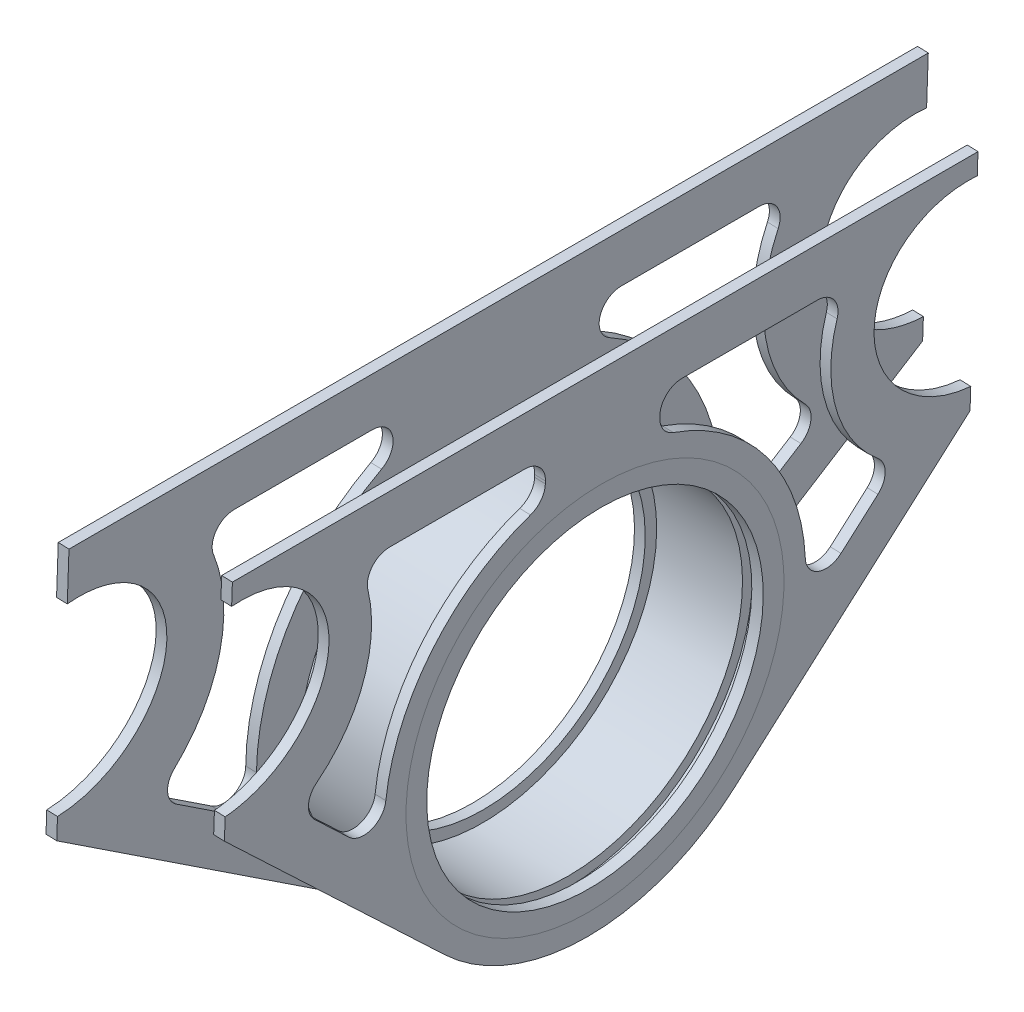
from build123d import *

# Parameters (mm, degrees)
SKETCH1_R                           = 12.7
SKETCH1_R_2                         = 10.668
STRUCTURAL_MEMBERLEFTDIAGTUBE_DEPTH = 435.613716129
EXTRUDEBEARINGCUP_START             = -8.2
SKETCH12_R                          = 26.4
SKETCH12_R_2                        = 23.5
EXTRUDEBEARINGCUP_DEPTH             = 16.4
SKETCH15_R                          = 23.5
SKETCH15_R_2                        = 21.9
BEARING_BACKSTOP_DEPTH              = 1.5
SKETCH24_R                          = 26.4
BOSS_EXTRUDEREARFLANGE_DEPTH        = 1.5
SKETCH16_R                          = 26.4
BOSS_EXTRUDEFRONTFLANGE_DEPTH       = 1.5
SKETCH20_R                          = 12.7
CUT_EXTRUDE1_DEPTH                  = 834.807291922
SKETCH26_R                          = 12.7
CUT_EXTRUDE2_DEPTH                  = 706.049293577


with BuildPart() as part:
    # Sketch1 → Structural MemberLeftDiagTube (new body)
    with BuildSketch(Plane(origin=(-742.278957466, 285.318954728, -26.691255907), x_dir=(0.4337677346733861, -0.1083105522192937, 0.894491127197062), z_dir=(-0.8944911271970621, -0.17110086067965116, 0.41304977767868617))):
        Circle(SKETCH1_R)
        Circle(SKETCH1_R_2, mode=Mode.SUBTRACT)
    extrude(amount=STRUCTURAL_MEMBERLEFTDIAGTUBE_DEPTH)


with BuildPart() as body_2:
    # MirrorRightDiagTube: mirrored copy
    add(part.part.mirror(Plane.XY.offset(-26.708200568)))


with BuildPart() as body_3:
    # Sketch12 → ExtrudeBearingCup (new body)
    with BuildSketch(Plane(origin=(-871.417099955, 30.430555679, 0), x_dir=(0, 0, -1), z_dir=(0.9993908270190963, -0.03489949670248751, 0)).offset(EXTRUDEBEARINGCUP_START)):
        with Locations(Location((26.708200568, 208.880792495, 0), (0, 0, 90))):
            Circle(SKETCH12_R)
        with Locations(Location((26.708200568, 208.880792495, 0), (0, 0, 90))):
            Circle(SKETCH12_R_2, mode=Mode.SUBTRACT)
    extrude(amount=EXTRUDEBEARINGCUP_DEPTH)

    # Sketch15 → Bearing Backstop (add)
    with BuildSketch(Plane(origin=(-879.612104737, 30.716731552, 0), x_dir=(0, 0, -1), z_dir=(0.9993908270190963, -0.034899496702487515, 0))):
        with Locations(Location((26.708200568, 208.880792495, 0), (0, 0, 90))):
            Circle(SKETCH15_R)
        with Locations(Location((26.708200568, 208.880792495, 0), (0, 0, 90))):
            Circle(SKETCH15_R_2, mode=Mode.SUBTRACT)
    extrude(amount=BEARING_BACKSTOP_DEPTH)

    # Sketch23 → Cut-RevolveSnapRingGroove (revolve, cut)
    with BuildSketch(Plane.XY.offset(-26.708200568), mode=Mode.PRIVATE) as cut_revolvesnapringgroove_sk:
        Polygon((-857.531285968, 238.953766961), (-858.400283436, 214.068935368), (-859.699491511, 214.114304714), (-858.830494043, 238.999136306), align=None)
    revolve(cut_revolvesnapringgroove_sk.sketch.rotate(Axis((-880.000118881, 239.738395896, -26.708200568), (0.9993908270190962, -0.03489949670248762, 0)), 180), axis=Axis((-880.000118881, 239.738395896, -26.708200568), (0.9993908270190962, -0.03489949670248762, 0)), mode=Mode.SUBTRACT)


with BuildPart() as body_4:
    # Sketch24 → Boss-ExtrudeRearFlange (new body)
    with BuildSketch(Plane(origin=(-863.222095173, 30.144379806, 0), x_dir=(0, 0, -1), z_dir=(0.9993908270190963, -0.034899496702487515, 0))):
        with BuildLine():
            Line((78.806239974, 246.71090197), (78.806239974, 249.71090197))
            Line((78.806239974, 249.71090197), (-25.389838838, 249.71090197))
            Line((-25.389838838, 249.71090197), (-25.389838838, 246.71090197))
            add(Edge.make_bspline(
                [(-25.389838838, 220.775104066), (-11.383096571, 221.994886497), (-11.383096571, 234.962785449), (-11.383096571, 247.930684401), (-25.389838838, 246.71090197)],
                knots=[1.160721876, 1.160721876, 1.160721876, 2.731518203, 2.731518203, 4.302314529, 4.302314529, 4.302314529], degree=2, weights=[1, 0.707106781, 1, 0.707106781, 1]))
            Line((-25.389838838, 220.775104066), (-25.389838838, 217.775104066))
            Line((-25.389838838, 217.775104066), (6.475538565, 187.550077826))
            ThreePointArc((6.475538565, 187.550077826), (26.708200568, 179.480792495), (46.94086257, 187.550077826))
            Line((46.94086257, 187.550077826), (78.806239974, 217.775104066))
            Line((78.806239974, 217.775104066), (78.806239974, 220.775104066))
            add(Edge.make_bspline(
                [(78.806239974, 246.71090197), (64.799497707, 247.930684401), (64.799497707, 234.962785449), (64.799497707, 221.994886497), (78.806239974, 220.775104066)],
                knots=[5.122463431, 5.122463431, 5.122463431, 6.693259758, 6.693259758, 8.264056085, 8.264056085, 8.264056085], degree=2, weights=[1, 0.707106781, 1, 0.707106781, 1]))
        make_face()
        with Locations(Location((26.708200568, 208.880792495, 0), (0, 0, 90))):
            Circle(SKETCH24_R, mode=Mode.SUBTRACT)
        with BuildLine():
            Line((-12.651994558, 213.962737757), (-7.658075134, 209.225893008))
            ThreePointArc((-7.658075134, 209.225893008), (-4.517205064, 208.602219609), (-2.602617939, 211.16900543))
            ThreePointArc((-2.602617939, 211.16900543), (3.323935367, 226.700336289), (16.726719086, 236.534544997))
            ThreePointArc((16.726719086, 236.534544997), (18.163353878, 237.632343071), (18.708200568, 239.356356477))
            Line((18.708200568, 239.356356477), (18.708200568, 239.71090197))
            ThreePointArc((18.708200568, 239.71090197), (17.829520911, 241.832222313), (15.708200568, 242.71090197))
            Line((15.708200568, 242.71090197), (-3.177585866, 242.71090197))
            ThreePointArc((-3.177585866, 242.71090197), (-5.558264845, 241.536379331), (-6.074836253, 238.932480367))
            ThreePointArc((-6.074836253, 238.932480367), (-6.310345755, 227.745258132), (-12.518185249, 218.435471084))
            ThreePointArc((-12.518185249, 218.435471084), (-13.5860956, 216.229051182), (-12.651994558, 213.962737757))
        make_face(mode=Mode.SUBTRACT)
        with BuildLine():
            Line((66.068395694, 213.962737757), (61.07447627, 209.225893008))
            ThreePointArc((61.07447627, 209.225893008), (57.9336062, 208.602219609), (56.019019075, 211.16900543))
            ThreePointArc((56.019019075, 211.16900543), (50.092465769, 226.700336289), (36.689682049, 236.534544997))
            ThreePointArc((36.689682049, 236.534544997), (35.253047257, 237.632343071), (34.708200568, 239.356356477))
            Line((34.708200568, 239.356356477), (34.708200568, 239.71090197))
            ThreePointArc((34.708200568, 239.71090197), (35.586880224, 241.832222313), (37.708200568, 242.71090197))
            Line((37.708200568, 242.71090197), (56.593987002, 242.71090197))
            ThreePointArc((56.593987002, 242.71090197), (58.974665981, 241.536379331), (59.491237389, 238.932480367))
            ThreePointArc((59.491237389, 238.932480367), (59.726746891, 227.745258132), (65.934586385, 218.435471084))
            ThreePointArc((65.934586385, 218.435471084), (67.002496736, 216.229051182), (66.068395694, 213.962737757))
        make_face(mode=Mode.SUBTRACT)
    extrude(amount=-BOSS_EXTRUDEREARFLANGE_DEPTH)


with BuildPart() as body_5:
    # Sketch16 → Boss-ExtrudeFrontFlange (new body)
    with BuildSketch(Plane(origin=(-879.612104737, 30.716731552, 0), x_dir=(0, 0, 1), z_dir=(-0.9993908270190963, 0.034899496702487515, 0))):
        with BuildLine():
            Line((33.333947306, 249.71090197), (-86.750348442, 249.71090197))
            Line((-86.750348442, 249.71090197), (-86.750348442, 242.945449778))
            add(Edge.make_bspline(
                [(-87.206665991, 216.992905829), (-72.667344737, 217.516199157), (-72.429971378, 231.01654018), (-72.192598019, 244.516881203), (-86.750348442, 242.945449778)],
                knots=[4.247183605, 4.247183605, 4.247183605, 5.856808636, 5.856808636, 7.466433668, 7.466433668, 7.466433668], degree=2, weights=[1, 0.693246367, 1, 0.693246367, 1]))
            Line((-87.206665991, 216.992905829), (-87.206665991, 213.992905829))
            Line((-87.206665991, 213.992905829), (-43.060097657, 184.4477112))
            ThreePointArc((-43.060097657, 184.4477112), (-26.709608396, 179.480792529), (-10.358643524, 184.446145281))
            Line((-10.358643524, 184.446145281), (33.798949952, 213.992595743))
            Line((33.798949952, 213.992595743), (33.798949952, 216.992595743))
            add(Edge.make_bspline(
                [(33.333947306, 242.945449778), (18.771672419, 244.517369595), (19.013641816, 231.012507832), (19.255611213, 217.50764607), (33.798949952, 216.992595743)],
                knots=[5.099936946, 5.099936946, 5.099936946, 6.709872488, 6.709872488, 8.319808029, 8.319808029, 8.319808029], degree=2, weights=[1, 0.693134466, 1, 0.693134466, 1]))
            Line((33.333947306, 242.945449778), (33.333947306, 249.71090197))
        make_face()
        with Locations(Location((-26.708200568, 208.880792495, 0), (0, 0, 270))):
            Circle(SKETCH16_R, mode=Mode.SUBTRACT)
        with BuildLine():
            Line((-70.339444305, 209.924197834), (-63.766251621, 205.52507318))
            ThreePointArc((-63.766251621, 205.52507318), (-60.652345168, 205.389371158), (-59.098581361, 208.091342008))
            ThreePointArc((-59.098581361, 208.091342008), (-54.884301087, 224.876646944), (-42.631108459, 237.098180828))
            ThreePointArc((-42.631108459, 237.098180828), (-41.203886392, 240.473081927), (-44.105451782, 242.71090197))
            Line((-44.105451782, 242.71090197), (-63.394456936, 242.71090197))
            ThreePointArc((-63.394456936, 242.71090197), (-65.89374993, 241.370279722), (-66.159304398, 238.546591654))
            ThreePointArc((-66.159304398, 238.546591654), (-64.834781938, 225.832558144), (-70.802559667, 214.528282988))
            ThreePointArc((-70.802559667, 214.528282988), (-71.655820689, 212.117120751), (-70.339444305, 209.924197834))
        make_face(mode=Mode.SUBTRACT)
        with BuildLine():
            Line((16.923043169, 209.924197834), (10.349850485, 205.52507318))
            ThreePointArc((10.349850485, 205.52507318), (7.235944032, 205.389371158), (5.682180225, 208.091342008))
            ThreePointArc((5.682180225, 208.091342008), (1.467899951, 224.876646944), (-10.785292677, 237.098180828))
            ThreePointArc((-10.785292677, 237.098180828), (-12.212514744, 240.473081927), (-9.310949354, 242.71090197))
            Line((-9.310949354, 242.71090197), (9.9780558, 242.71090197))
            ThreePointArc((9.9780558, 242.71090197), (12.477348795, 241.370279722), (12.742903262, 238.546591654))
            ThreePointArc((12.742903262, 238.546591654), (11.418380802, 225.832558144), (17.386158531, 214.528282988))
            ThreePointArc((17.386158531, 214.528282988), (18.239419553, 212.117120751), (16.923043169, 209.924197834))
        make_face(mode=Mode.SUBTRACT)
    extrude(amount=-BOSS_EXTRUDEFRONTFLANGE_DEPTH)


with BuildPart() as cut_extrude1_tool:
    # Sketch20 → Cut-Extrude1 (new, through all)
    with BuildSketch(Plane(origin=(-928.95736894, -184.712015501, 428.965277628), x_dir=(0.40512847183893946, 0.08055133977062362, 0.9107043444316071), z_dir=(-0.8944911271970621, -0.1711008606796512, 0.41304977767868617))):
        with Locations((-301.478020707, 427.495628267)):
            Circle(SKETCH20_R)
    extrude(amount=-CUT_EXTRUDE1_DEPTH)


with BuildPart() as body_2_1:
    add(body_2.part)

    # Cut-Extrude1: cut by cut_extrude1_tool
    add(cut_extrude1_tool.part, mode=Mode.SUBTRACT)

    # Sketch26 → Cut-Extrude2 (cut, through all)
    with BuildSketch(Plane(origin=(-949.767238699, -181.674235826, -438.574665375), x_dir=(-0.4056944471820776, -0.07760241211483396, 0.9107084501417498), z_dir=(-0.8944911271970621, -0.1711008606796512, -0.41304977767868617))):
        with Locations((254.658196603, 419.695064707)):
            Circle(SKETCH26_R)
    extrude(amount=-CUT_EXTRUDE2_DEPTH, mode=Mode.SUBTRACT)


with BuildPart() as part_1:
    add(part.part)

    # Cut-Extrude1: cut by cut_extrude1_tool
    add(cut_extrude1_tool.part, mode=Mode.SUBTRACT)


solid = Compound([body_3.part, body_4.part, body_5.part])
